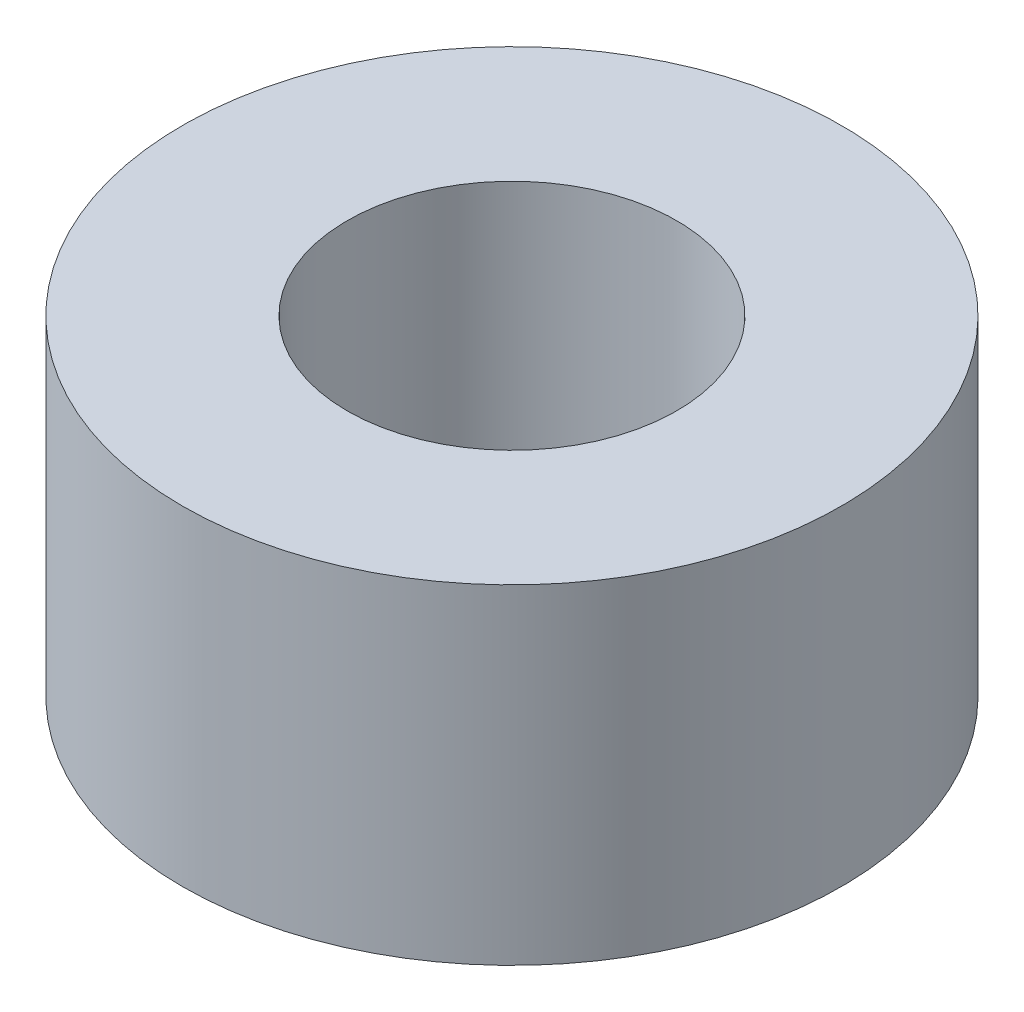
from build123d import *

# Parameters (mm, degrees)
SKETCH1_R           = 5
BOSS_EXTRUDE1_DEPTH = 5
SKETCH2_R           = 2.5
CUT_EXTRUDE1_DEPTH  = 6


with BuildPart() as part:
    # Sketch1 → Boss-Extrude1 (new body)
    with BuildSketch(Plane(origin=(0, 0, 0), x_dir=(1, 0, 0), z_dir=(0, 1, 0))):
        Circle(SKETCH1_R)
    extrude(amount=BOSS_EXTRUDE1_DEPTH)

    # Sketch2 → Cut-Extrude1 (cut, through all)
    with BuildSketch(Plane(origin=(0, 5, 0), x_dir=(1, 0, 0), z_dir=(0, 1, 0))):
        Circle(SKETCH2_R)
    extrude(amount=-CUT_EXTRUDE1_DEPTH, mode=Mode.SUBTRACT)


solid = part.part
